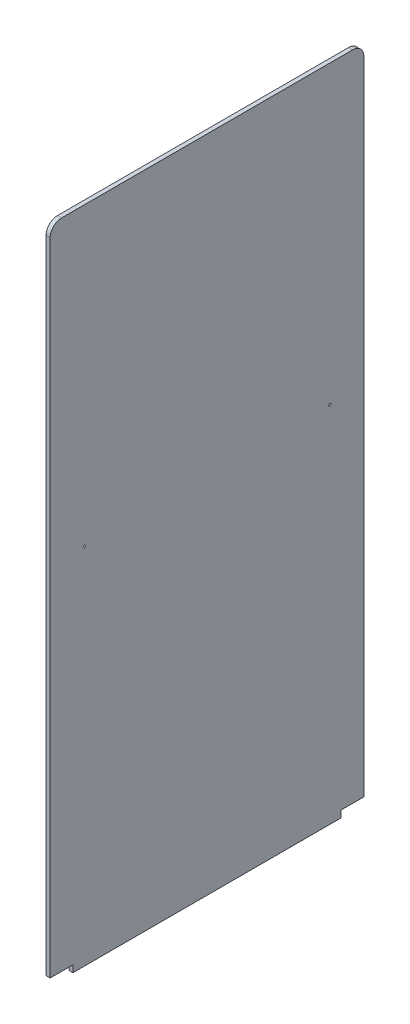
from build123d import *

# Parameters (mm, degrees)
SKETCH1_W           = 138
SKETCH1_H           = 290
BOSS_EXTRUDE1_DEPTH = 0.9
SKETCH2_W           = 24.039147707
SKETCH2_H           = 8.338300827
CUT_EXTRUDE1_DEPTH  = 3
SKETCH4_R           = 0.5
CUT_EXTRUDE2_DEPTH  = 10
FILLET1_R           = 5


with BuildPart() as part:
    # Sketch1 → Boss-Extrude1 (new, symmetric)
    with BuildSketch(Plane(origin=(0, 0, 0), x_dir=(0, 0, -1), z_dir=(1, 0, 0))):
        with Locations((0, 142)):
            Rectangle(SKETCH1_W, SKETCH1_H)
    extrude(amount=BOSS_EXTRUDE1_DEPTH, both=True)

    # Sketch2 → Cut-Extrude1 (cut)
    with BuildSketch(Plane(origin=(0.9, 0, 0), x_dir=(0, 0, -1), z_dir=(1, 0, 0))):
        with Locations((71.019573854, -4.169150414)):
            Rectangle(SKETCH2_W, SKETCH2_H)
        with Locations((-71.019573854, -4.169150414)):
            Rectangle(SKETCH2_W, SKETCH2_H)
    extrude(amount=-CUT_EXTRUDE1_DEPTH, mode=Mode.SUBTRACT)

    # Sketch4 → Cut-Extrude2 (cut)
    with BuildSketch(Plane(origin=(0.9, 0, 0), x_dir=(0, 0, -1), z_dir=(1, 0, 0))):
        with Locations((-54, 156.83912074)):
            Circle(SKETCH4_R)
        with Locations((54, 156.83912074)):
            Circle(SKETCH4_R)
    extrude(amount=-CUT_EXTRUDE2_DEPTH, mode=Mode.SUBTRACT)

    # Fillet1
    fillet1_edges = [part.edges().sort_by_distance(p)[0] for p in [
        (0, 287, -69),
        (0, 287, 69),
    ]]
    fillet(fillet1_edges, radius=FILLET1_R)


solid = part.part
